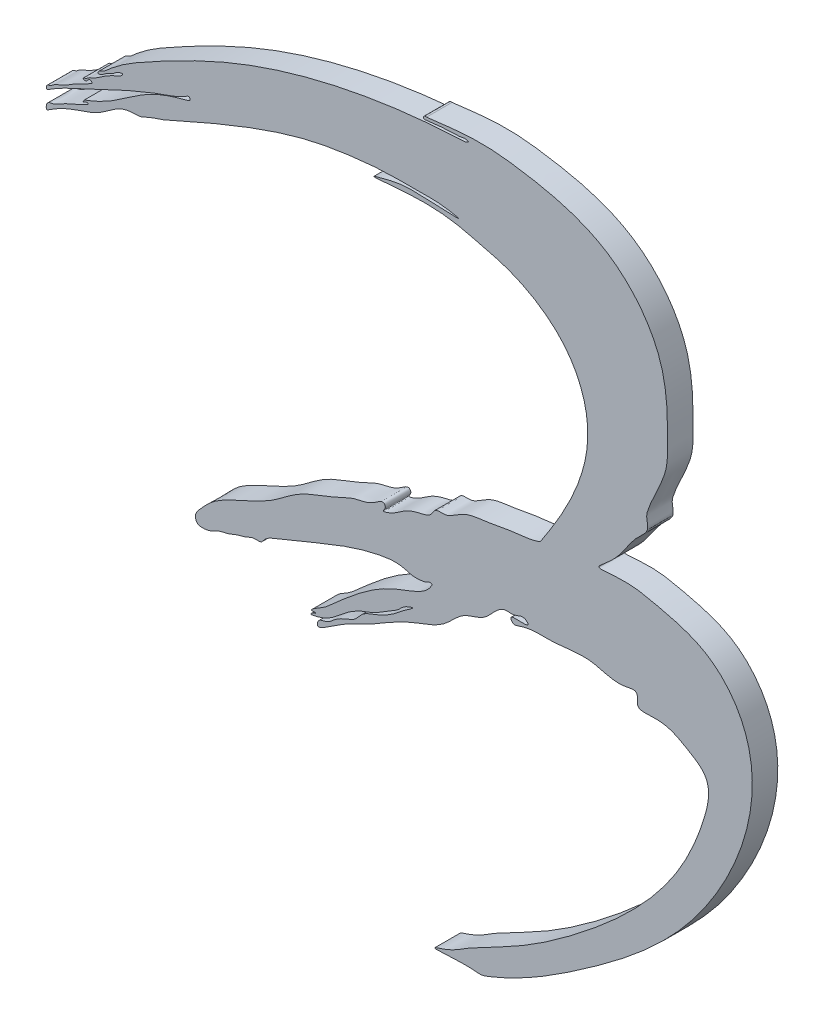
from build123d import *

# Parameters (mm, degrees)
BOSS_EXTRU_1_DEPTH = 3


with BuildPart() as part:
    # Esquisse1 → Boss.-Extru.1 (new body)
    with BuildSketch(Plane.XY):
        with BuildLine():
            add(Edge.make_bspline(
                [(15.199501596, 5.19827013), (17.821833875, 9.183383275), (22.629000949, 16.971227456), (18.587447692, 27.501142532), (12.553165944, 30.899865523), (6.467142022, 32.336154462), (3.433568066, 33.434127811), (-5.770512028, 32.324943728), (-1.58227749, 33.386029511), (0.11809062, 33.6057321), (7.302757441, 33.077735479), (3.141684449, 33.832405539), (1.017993336, 33.689793167), (-2.647236245, 33.799293666), (-7.445845477, 33.366429245), (-15.92003306, 31.932697487), (-26.701556747, 27.057728234), (-29.295958162, 25.899656594), (-30.790313218, 25.464172279), (-31.498220123, 25.013268287), (-32.392292528, 24.908707224), (-34.386234324, 24.965098221), (-36.040487773, 22.885836342), (-39.711873597, 21.831002358), (-41.502541813, 21.017301699), (-42.899901567, 20.059980456), (-42.871608491, 21.122992506), (-41.936451138, 21.075515631), (-40.455272075, 22.100323687), (-39.382838325, 22.353291806), (-37.822686797, 23.223027137), (-38.228826553, 23.34318535), (-38.620072584, 22.967870193), (-38.453301779, 23.259334997), (-38.381861279, 23.376759578), (-38.378682104, 23.381970776)],
                knots=[0, 0, 0, 0, 0.034118173, 0.050236448, 0.068967481, 0.073500141, 0.095563045, 0.104190877, 0.107921759, 0.116908237, 0.126964302, 0.130310205, 0.137621374, 0.144820214, 0.154992728, 0.171421939, 0.207781336, 0.216895984, 0.219190241, 0.229442387, 0.232264538, 0.246130236, 0.386672642, 0.489153724, 0.601852187, 0.608768219, 0.628383974, 0.656973958, 0.68694343, 0.800374789, 0.80697629, 0.814481946, 0.827884702, 0.837106078, 0.837535097, 0.837535097, 0.837535097, 0.837535097], degree=3))
            add(Edge.make_bspline(
                [(-38.378682104, 23.381970776), (-33.151500906, 25.27166131), (-32.809920673, 27.872248644), (-25.787981842, 29.497955347), (-26.103538738, 29.930492256), (-26.507553428, 29.692995214), (-27.360521745, 29.16552524), (-30.14111601, 28.252554063), (-34.137978212, 26.578270453), (-38.859204285, 24.222944944), (-41.309869859, 23.196256236), (-42.874110309, 22.150391358), (-42.853829074, 22.792306223), (-42.348259232, 22.794141871), (-41.860375174, 23.295583602), (-40.814603077, 23.568119398), (-39.698827779, 24.409215193), (-38.461511387, 24.911089892), (-37.853637417, 25.319881346), (-37.358137169, 25.558094256), (-37.770730538, 25.876427723), (-38.000933013, 25.536274622), (-38.278449034, 25.324868277), (-38.620704246, 25.570383325), (-38.149927254, 25.641939549), (-37.869464205, 25.944545015), (-37.03294802, 26.2424661), (-36.032779709, 27.020817592), (-34.849532896, 27.654985639), (-34.091436034, 27.935839495), (-33.784642378, 28.332593873), (-34.574483589, 28.213168014), (-34.921493986, 27.680212694), (-35.927327309, 27.390762754), (-36.3188987, 26.895480436), (-36.801377521, 26.878923203), (-36.670879334, 27.290250395), (-36.170684675, 27.370362246), (-35.589905209, 27.8734543), (-34.012328886, 29.2498972), (-28.988450227, 32.130336463), (-17.470443336, 37.947850868), (-4.495867131, 40.802208637), (4.57388912, 41.419790355), (6.376830738, 41.498112846), (6.573306634, 41.535255858), (6.816934834, 41.718502901), (6.344825058, 41.883095175), (5.8229147, 41.665150553), (5.060979207, 41.708307088), (4.774639109, 41.675267845)],
                knots=[0, 0, 0, 0, 0.134847579, 0.143034237, 0.144601639, 0.148638772, 0.154180377, 0.178067515, 0.234677611, 0.292201023, 0.330745501, 0.333193175, 0.337239427, 0.34163035, 0.346584802, 0.358071859, 0.373748347, 0.389768442, 0.396912852, 0.399366253, 0.402749079, 0.40598643, 0.410304005, 0.412055835, 0.415102654, 0.419095224, 0.426513149, 0.440578697, 0.458947906, 0.465949143, 0.46750081, 0.470952025, 0.480463688, 0.491216585, 0.499184075, 0.500837468, 0.502285256, 0.509315764, 0.515195501, 0.525664095, 0.573905162, 0.691976912, 0.92332858, 0.972552013, 0.974530944, 0.977935359, 0.979470166, 0.981332426, 0.988581693, 1, 1, 1, 1], degree=3))
            add(Edge.make_bspline(
                [(4.774639109, 41.675267845), (4.760803818, 41.687996313), (2.671820513, 41.587578359), (1.60787378, 41.384083364), (1.423328249, 41.478627344), (1.551654818, 41.759790589), (1.662285876, 41.745802763), (1.83862317, 41.745802763)],
                knots=[0, 0, 0, 0, 0.789100761, 0.825841685, 0.866784773, 0.917493908, 1, 1, 1, 1], degree=3))
            add(Edge.make_bspline(
                [(1.83862317, 41.745802763), (4.201800044, 42.026548884), (7.965227852, 42.543681936), (15.377537811, 41.600383021), (23.754542689, 39.606839104), (30.242361011, 31.076153004), (30.174726072, 24.516335954), (30.158916907, 19.125485991), (28.323879587, 16.340307286), (27.587397297, 13.873056817), (28.131520854, 12.663689238), (26.40075046, 11.268224295), (25.004357473, 9.154253691), (23.826987881, 7.582169808), (21.511451775, 5.819913561), (25.580707552, 6.334753322), (28.71221984, 5.62982261), (35.028487912, 4.197237385), (42.899901567, -5.080382226), (36.188617846, -23.566629927), (22.391386767, -34.613541924), (12.98951267, -40.618585786), (8.256907238, -42.425006734), (6.968491784, -42.249871811), (5.508728267, -42.27472829), (1.758802816, -42.543681936), (4.738646405, -41.717421307), (7.034027075, -40.083380879), (12.65356979, -37.455394119), (20.524525181, -32.089972711), (29.375033553, -24.225276217), (33.928983956, -16.026611157), (35.582044813, -9.071070171), (31.944243877, -6.930120121), (29.819938636, -5.722460455), (26.519353522, -6.239631422), (26.681847386, -5.1156838), (26.571218073, -4.171485179), (24.062546236, -4.980149617), (21.217607914, -3.473398055), (16.783439389, -4.464366384), (13.881560029, -4.091277119), (12.049471654, -4.909167772), (11.529921439, -4.013140009), (12.732739638, -4.107057841), (14.063430877, -4.09489587), (13.15126826, -3.208188584), (12.250684629, -3.955381689), (10.347925444, -3.533078373), (9.052934091, -6.101505467), (6.008596073, -6.490326167), (3.698575097, -9.522030954), (-0.600839716, -10.479384464), (-5.011878016, -13.541408597), (-7.47431087, -14.233312629), (-11.170549406, -17.019321239), (-10.868532927, -15.599201661), (-9.799796267, -15.621998192), (-8.934063686, -14.701468685), (-7.79472109, -14.091686751), (-6.48225912, -13.661321926), (-5.675604177, -12.375832772), (-3.865234922, -11.87561888), (-1.981937073, -10.806291667), (-1.027313928, -9.903827905), (0.674975578, -8.807715989), (-0.903376936, -9.349386703), (-1.398336032, -10.076246783), (-2.83709933, -10.842382907), (-4.134960591, -11.80547712), (-6.008386977, -12.384951899), (-8.416228937, -13.805069763), (-9.506595337, -15.331173886), (-11.841272792, -15.700735402), (-11.525452522, -15.343641859), (-11.518938915, -15.42796626), (-11.22191417, -15.29127299)],
                knots=[0, 0, 0, 0, 0.026687041, 0.041758511, 0.083493474, 0.118973002, 0.150540371, 0.156597534, 0.176994959, 0.18017269, 0.185825157, 0.191479594, 0.201603433, 0.213817923, 0.218106659, 0.223795932, 0.242243458, 0.266099554, 0.288781538, 0.369710272, 0.440444573, 0.490023006, 0.491708173, 0.496504241, 0.503315345, 0.512757585, 0.517466541, 0.527117388, 0.549027526, 0.582504712, 0.63508691, 0.675369094, 0.692163791, 0.702025976, 0.717110337, 0.724426756, 0.726291893, 0.728748425, 0.733278045, 0.748050913, 0.765920834, 0.779574845, 0.782783307, 0.784336954, 0.788151912, 0.791966871, 0.79347413, 0.798862712, 0.802060091, 0.813838189, 0.823241002, 0.834393423, 0.85328146, 0.871386034, 0.888313364, 0.896675766, 0.89777436, 0.902184864, 0.905808952, 0.91165869, 0.916425933, 0.920642695, 0.927542642, 0.936656222, 0.942844494, 0.946607064, 0.949757772, 0.954208113, 0.957935126, 0.967061389, 0.972245786, 0.979627044, 0.996876113, 0.997505843, 0.998262685, 1, 1, 1, 1], degree=3))
            add(Edge.make_bspline(
                [(-11.22191417, -15.29127299), (-11.186266764, -15.124088641), (-11.429834985, -15.253807068), (-11.780350866, -15.221582917), (-11.414774009, -14.90799667), (-10.989300607, -14.630931079), (-9.945852898, -14.058003537), (-8.588838509, -12.774282026), (-5.882423151, -10.421572507), (-2.320279206, -7.975605625), (1.704685174, -6.953678961), (2.446253852, -5.628195526), (2.549533359, -5.456959728), (2.103521886, -5.351291027), (1.777117428, -5.671600424), (1.011243916, -5.764776083), (0.165009296, -5.816292013), (-0.890788083, -5.42422225), (-2.065453773, -5.335222804), (-4.704482206, -5.7145082), (-8.052423489, -6.773041324), (-12.217201184, -8.532565943), (-15.162724673, -9.673613359), (-17.086609685, -10.526886626), (-17.604509095, -11.377201508), (-18.553728659, -11.139307999), (-19.359189647, -11.666080336), (-20.495872405, -11.86737146), (-21.420659909, -12.376879658), (-22.554544298, -12.509439682), (-23.374481711, -13.060618435), (-24.264794986, -13.259020548), (-25.189023581, -13.209642404), (-25.4534214, -12.206542129), (-24.56322207, -11.219945232), (-23.194644984, -9.69219821), (-20.078511055, -8.196996222), (-16.409016186, -6.666936221), (-13.043872582, -3.717207164), (-9.54150942, -2.723696465), (-6.624506686, -1.14249), (-4.74300044, -1.070415059), (-3.250382499, 0.283024268), (-2.910352487, -0.473377103), (-3.492997458, -1.063414753), (-2.190803406, -0.623235529), (-1.548049956, -0.183676376), (-0.361872164, 0.658241758), (0.980198169, 1.048957658), (2.363432609, 1.301029537), (2.830110202, 2.498904618), (3.934371409, 2.247245707), (5.081917906, 2.773748574), (6.527013108, 3.87514312), (9.047877847, 4.035609544), (11.96042957, 4.717009799), (14.095841953, 4.773964642), (15.199501596, 5.19827013)],
                knots=[0, 0, 0, 0, 0.003834771, 0.005625769, 0.008650413, 0.013337213, 0.025484996, 0.043793879, 0.074034413, 0.138519412, 0.186487406, 0.188035725, 0.189270321, 0.191768902, 0.197818485, 0.204073543, 0.21530722, 0.224788642, 0.239449454, 0.252378597, 0.309642938, 0.350812124, 0.396294991, 0.411558776, 0.416284588, 0.425569842, 0.43728448, 0.446181137, 0.462020104, 0.470349452, 0.482049517, 0.492444261, 0.500051468, 0.507957674, 0.519114075, 0.539936082, 0.57420713, 0.626741522, 0.66709193, 0.713692614, 0.742757768, 0.767935224, 0.78126626, 0.7848311, 0.790075173, 0.797680908, 0.809788701, 0.82317486, 0.840569523, 0.856115471, 0.863527385, 0.876385841, 0.884884293, 0.903946939, 0.932867387, 0.962688937, 1, 1, 1, 1], degree=3))
        make_face()
    extrude(amount=BOSS_EXTRU_1_DEPTH)


solid = part.part
